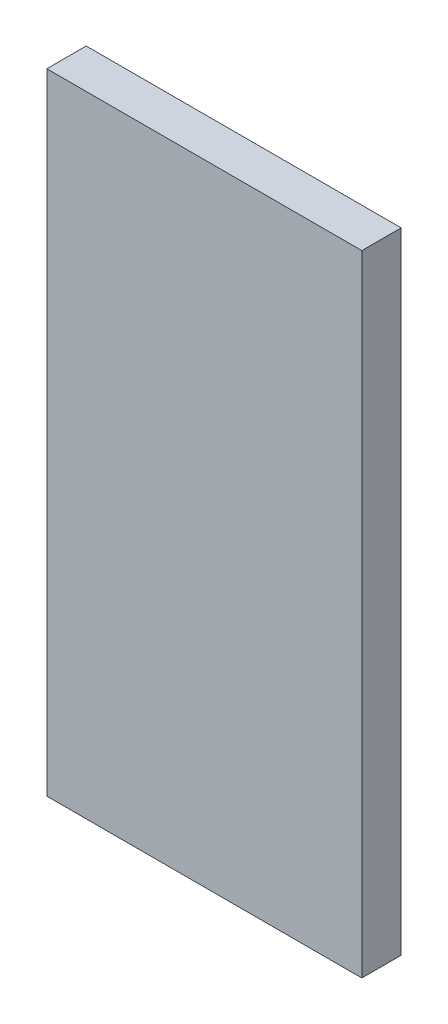
from build123d import *

# Parameters (mm, degrees)
SKETCH1_W           = 25.4
SKETCH1_H           = 50.8
BOSS_EXTRUDE1_DEPTH = 1.5875


with BuildPart() as part:
    # Sketch1 → Boss-Extrude1 (new body, symmetric)
    with BuildSketch(Plane.XY):
        Rectangle(SKETCH1_W, SKETCH1_H)
    extrude(amount=BOSS_EXTRUDE1_DEPTH, both=True)


solid = part.part
